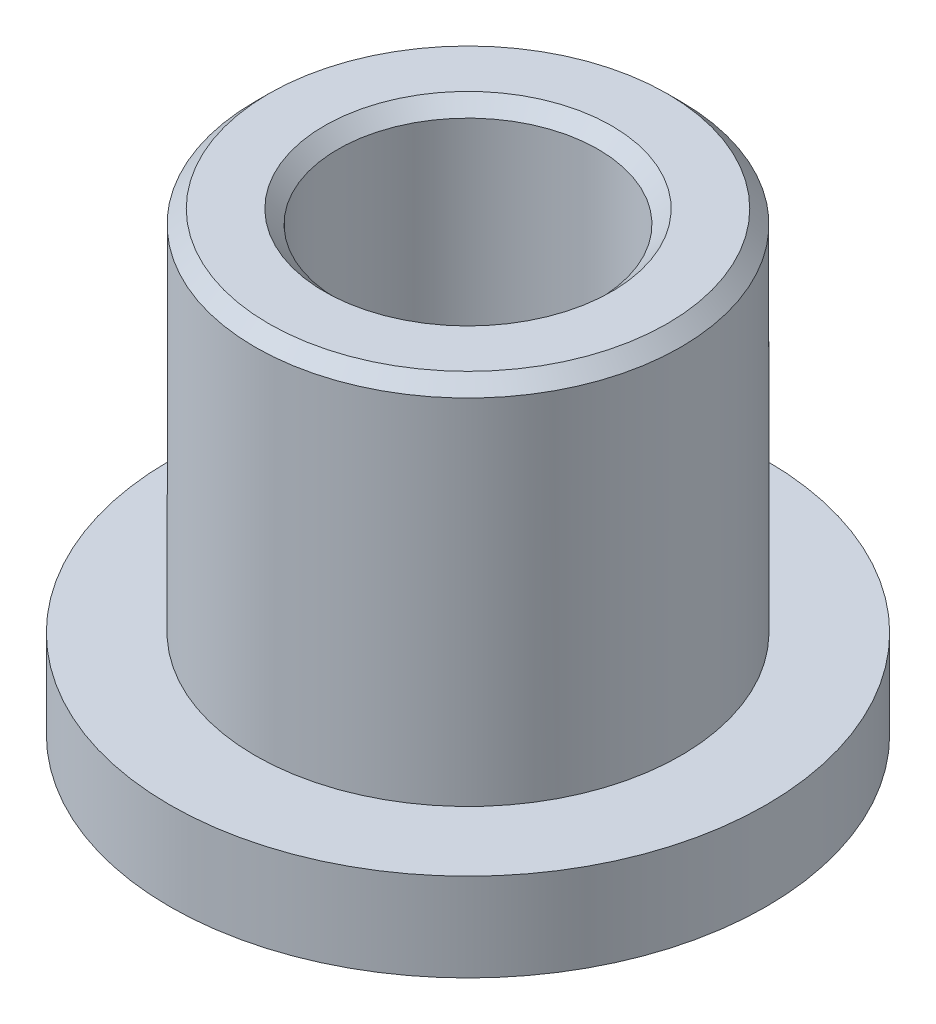
from build123d import *

# Parameters (mm, degrees)
CUT_EXTRUDE1_DEPTH      = 15.637622758
CUT_EXTRUDE1_DEPTH_BACK = 15.637622758
SKETCH2_W               = 14
SKETCH2_H               = 8
CHAMFER1_SIZE           = 0.25


with BuildPart() as part:
    # Sketch1 → Revolve1 (revolve)
    with BuildSketch(Plane.XY):
        Polygon((3.925, 1.6256), (3.925, 12.4), (2.4, 12.4), (2.4, 0.2), (2.6, 0), (5.5, 0), (5.5, 1.6256), align=None)
    revolve(axis=Axis((0, 0, 0), (0, -1, 0)))

    # Sketch2 → Cut-Extrude1 (cut, two sides: drawn at the far end of the back side and taken through both)
    with BuildSketch(Plane.XY.offset(-CUT_EXTRUDE1_DEPTH_BACK)):
        with Locations((0, 12.4)):
            Rectangle(SKETCH2_W, SKETCH2_H)
    extrude(amount=CUT_EXTRUDE1_DEPTH + CUT_EXTRUDE1_DEPTH_BACK, mode=Mode.SUBTRACT)

    # Chamfer1
    chamfer1_edges = [part.edges().sort_by_distance(p)[0] for p in [
        (-2.4, 8.4, 0),
        (-3.925, 8.4, 0),
    ]]
    chamfer(chamfer1_edges, length=CHAMFER1_SIZE)


solid = part.part
